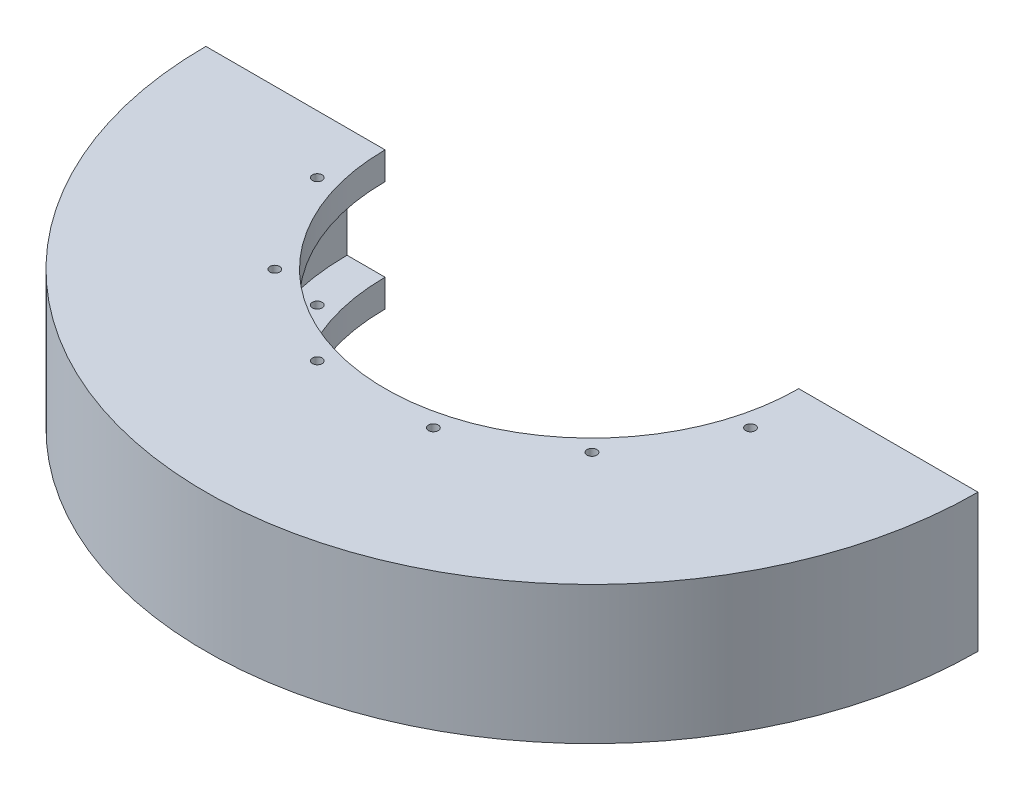
from build123d import *

# Parameters (mm, degrees)
REVOLVE1_ANGLE            = 180
TAP_DRILL_FOR_4_40_TAP1_D = 2.2606
CIRPATTERN1_COUNT         = 12


with BuildPart() as part:
    # Sketch1 → Revolve1 (revolve)
    with BuildSketch(Plane.XY):
        Polygon((56.388, 0), (56.388, 9.525), (47.625, 9.525), (47.625, 15.875), (88.9, 15.875), (88.9, -15.875), (47.625, -15.875), (47.625, -9.525), (56.388, -9.525), align=None)
    revolve(axis=Axis((0, 22.539286723, 0), (0, -1, 0)), revolution_arc=REVOLVE1_ANGLE)

    # Tap Drill for #4-40 Tap1 (through all)
    with Locations(Plane(origin=(49.878671003, 15.875, 13.364949615), x_dir=(0, 0, 1), z_dir=(0, 1, 0))):
        with Locations((0, 0)):
            tap_drill_for_4_40_tap1 = Hole(TAP_DRILL_FOR_4_40_TAP1_D / 2)

    # CirPattern1: Tap Drill for #4-40 Tap1 ×12 about axis, 6 skipped
    cirpattern1_axis = Axis((0, 15.875, 0), (0, 1, 0))
    add([tap_drill_for_4_40_tap1.rotate(cirpattern1_axis, i * 360 / CIRPATTERN1_COUNT) for i in range(1, CIRPATTERN1_COUNT) if i not in (1, 2, 3, 4, 5, 6)], mode=Mode.SUBTRACT)


solid = part.part
